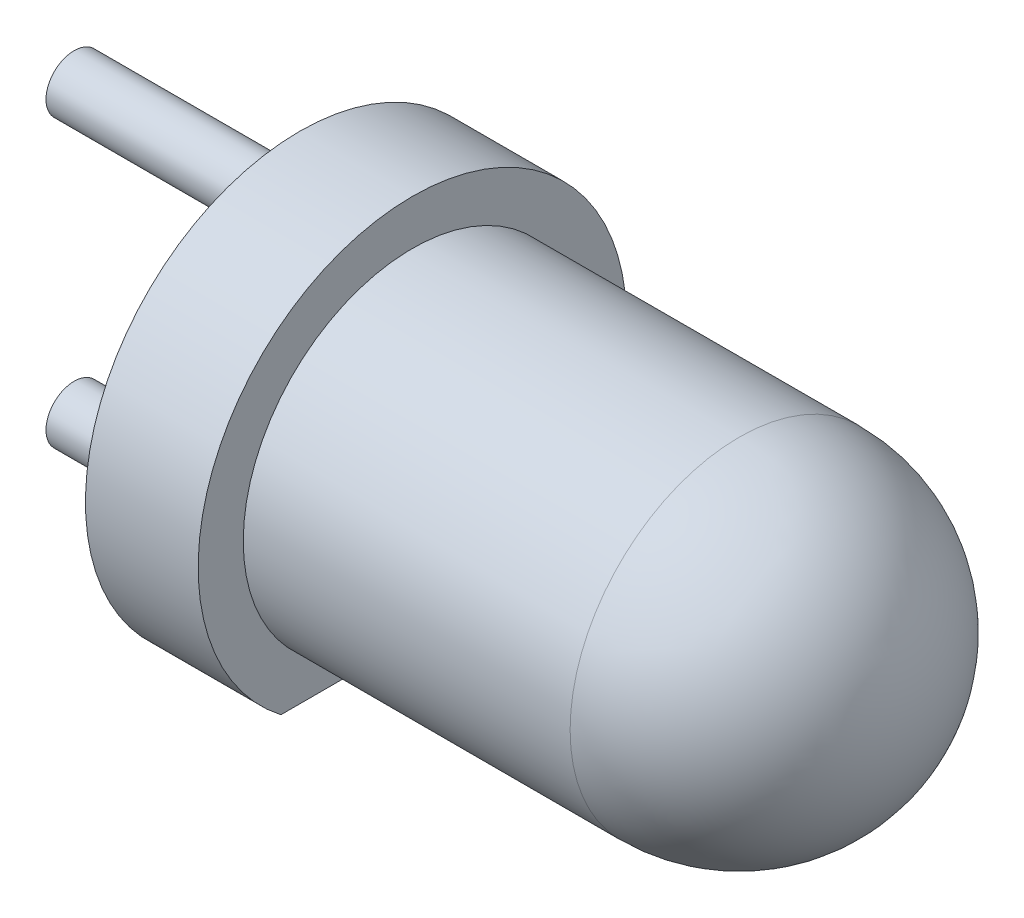
from build123d import *

# Parameters (mm, degrees)
ESQUISSE2_R             = 0.25
EXTRUSION1_DEPTH        = 2
ESQUISSE3_W             = 3.802685038
ESQUISSE3_H             = 0.717288717
ENL_V_MAT_EXTRU_1_DEPTH = 4


with BuildPart() as part:
    # Esquisse1 → Révolution1 (revolve)
    with BuildSketch(Plane.XY, mode=Mode.PRIVATE) as r_volution1_sk:
        with BuildLine():
            Line((0, 0), (4.4, 0))
            ThreePointArc((4.4, 0), (3.960660172, 1.060660172), (2.9, 1.5))
            Line((2.9, 1.5), (0, 1.5))
            Line((0, 1.5), (0, 1.9))
            Line((0, 1.9), (-1, 1.9))
            Line((-1, 1.9), (-1, 0))
            Line((-1, 0), (0, 0))
        make_face()
    revolve(r_volution1_sk.sketch.rotate(Axis((0, 0, 0), (1, 0, 0)), 90), axis=Axis((0, 0, 0), (1, 0, 0)))  # turned: the seam where the file's is

    # Esquisse2 → Extrusion1 (add)
    with BuildSketch(Plane.ZY.offset(1)):
        with Locations(Location((0, 1.27, 0), (0, 0, 180))):  # turned: the seam where the file's is
            Circle(ESQUISSE2_R)
        with Locations(Location((0, -1.27, 0), (0, 0, 180))):  # turned: the seam where the file's is
            Circle(ESQUISSE2_R)
    extrude(amount=EXTRUSION1_DEPTH)

    # Esquisse3 → Enlèv. mat.-Extru.1 (cut)
    with BuildSketch(Plane.ZY.offset(1)):
        with Locations((0.034282181, -1.858644359)):
            Rectangle(ESQUISSE3_W, ESQUISSE3_H)
    extrude(amount=-ENL_V_MAT_EXTRU_1_DEPTH, mode=Mode.SUBTRACT)


solid = part.part
